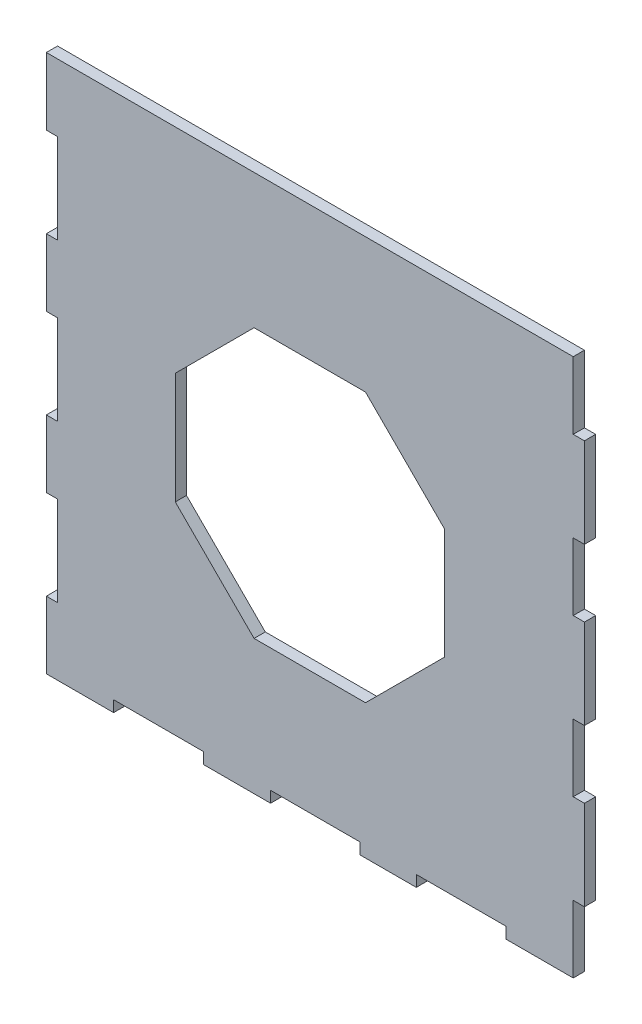
from build123d import *

# Parameters (mm, degrees)
SKETCH1_W           = 3.175
SKETCH1_H           = 25.4
BOSS_EXTRUDE1_DEPTH = 3.175
CUT_EXTRUDE1_DEPTH  = 4.175


with BuildPart() as part:
    # Sketch1 → Boss-Extrude1 (new body)
    with BuildSketch(Plane.XY):
        Polygon((55.5625, -76.2), (74.6125, -76.2), (74.6125, -57.15), (74.6125, -31.75), (74.6125, -12.7), (74.6125, 12.7), (74.6125, 31.75), (74.6125, 57.15), (74.6125, 76.2), (-74.6125, 76.2), (-74.6125, 57.15), (-71.4375, 57.15), (-71.4375, 31.75), (-74.6125, 31.75), (-74.6125, 12.7), (-71.4375, 12.7), (-71.4375, -12.7), (-74.6125, -12.7), (-74.6125, -31.75), (-71.4375, -31.75), (-71.4375, -57.15), (-74.6125, -57.15), (-74.6125, -76.2), (-55.5625, -76.2), (-55.5625, -73.025), (-30.1625, -73.025), (-30.1625, -76.2), (-11.1125, -76.2), (-11.1125, -73.025), (14.2875, -73.025), (14.2875, -76.2), (30.1625, -76.2), (30.1625, -73.025), (55.5625, -73.025), align=None)
        with Locations((76.2, 44.45)):
            Rectangle(SKETCH1_W, SKETCH1_H)
        with Locations((76.2, 0)):
            Rectangle(SKETCH1_W, SKETCH1_H)
        with Locations((76.2, -44.45)):
            Rectangle(SKETCH1_W, SKETCH1_H)
    extrude(amount=BOSS_EXTRUDE1_DEPTH)

    # Sketch2 → Cut-Extrude1 (cut, through all)
    with BuildSketch(Plane.XY.offset(3.175)):
        Polygon((-15.781536726, 38.1), (-38.1, 15.781536726), (-38.1, -15.781536726), (-15.781536726, -38.1), (15.781536726, -38.1), (38.1, -15.781536726), (38.1, 15.781536726), (15.781536726, 38.1), align=None)
    extrude(amount=-CUT_EXTRUDE1_DEPTH, mode=Mode.SUBTRACT)


solid = part.part
